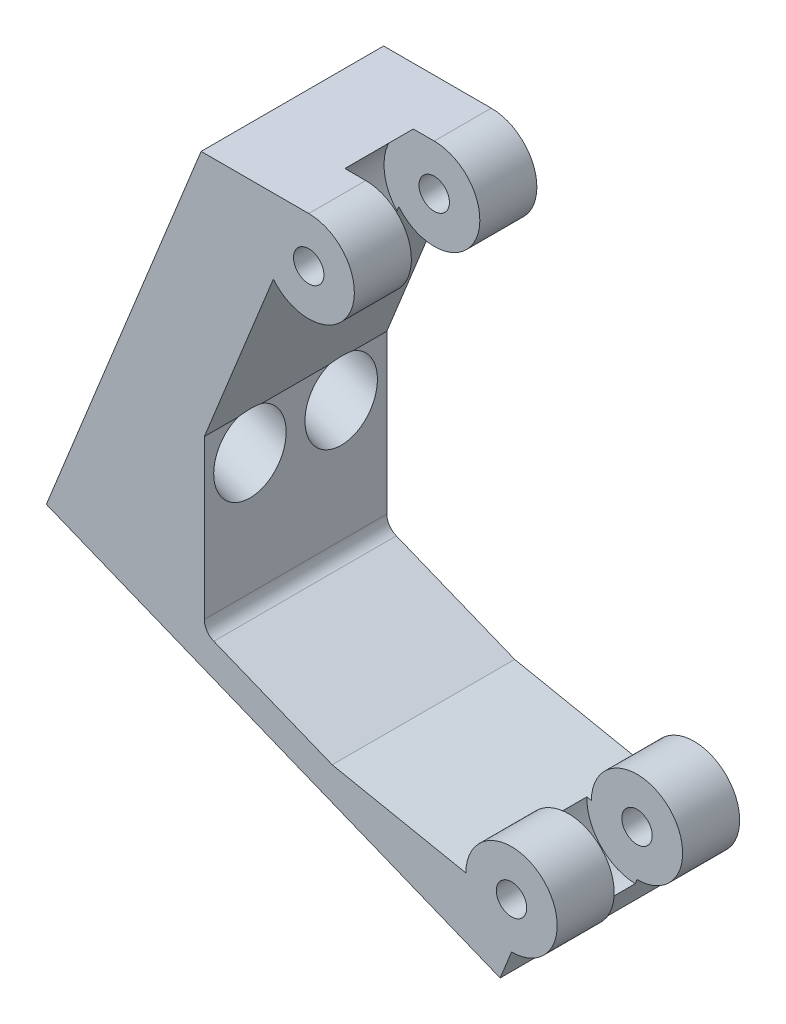
from build123d import *

# Parameters (mm, degrees)
SKETCH1_R                     = 1
BOSS_EXTRUDE1_DEPTH           = 12
SKETCH2_R                     = 3.3
CUT_EXTRUDE1_DEPTH            = 2.25
CUT_EXTRUDE1_DEPTH_BACK       = 2.25
FILLET3_R                     = 1
BOSS_EXTRUDE2_REACH           = 51.61
SKETCH4_W                     = 12
SKETCH4_H                     = 26.489515253
HOLE_SKETCH_R                 = 1.288405797
SCREW_SHAFT_HOLES_DEPTH       = 42.118659034
SCREW_SHAFT_HOLES_DEPTH_BACK  = 42.118659034
SKETCH5_R                     = 2.38125
SCREW_COUNTERBORES_DEPTH      = 5
SCREW_COUNTERBORES_DEPTH_BACK = 2.591836735
SKETCH6_W                     = 18.725223932
SKETCH6_H                     = 35.053619202
CUT_EXTRUDE2_DEPTH            = 1.66


with BuildPart() as part:
    # Sketch1 → Boss-Extrude1 (new body)
    with BuildSketch(Plane.XY):
        with BuildLine():
            Line((0, 6.640670196), (0, 35.210532713))
            Line((0, 35.210532713), (8.865440207, 35.210532713))
            ThreePointArc((8.865440207, 35.210532713), (11.575609349, 30.924071201), (6.541088012, 30.31385486))
            Line((6.541088012, 30.31385486), (2, 19.07426762))
            Line((2, 19.07426762), (2, 7.989687229))
            Line((2, 7.989687229), (10.406938735, 4.593063501))
            Line((10.406938735, 4.593063501), (19.199232805, 2.828667434))
            ThreePointArc((19.199232805, 2.828667434), (24.320553148, 4.949987778), (22.199232805, -0.171332566))
            Line((22.199232805, -0.171332566), (21.450019618, -2.025700275))
            Line((21.450019618, -2.025700275), (0, 6.640670196))
        make_face()
        with Locations((8.865440207, 32.210532713)):
            Circle(SKETCH1_R, mode=Mode.SUBTRACT)
        with Locations((22.199232805, 2.828667434)):
            Circle(SKETCH1_R, mode=Mode.SUBTRACT)
    extrude(amount=BOSS_EXTRUDE1_DEPTH)

    # Sketch2 → Cut-Extrude1 (cut, two sides)
    with BuildSketch(Plane.XY.offset(6)) as cut_extrude1_sk:
        with Locations((8.865440207, 32.210532713)):
            Circle(SKETCH2_R)
        with Locations((22.199232805, 2.828667434)):
            Circle(SKETCH2_R)
    extrude(amount=CUT_EXTRUDE1_DEPTH, mode=Mode.SUBTRACT)
    extrude(cut_extrude1_sk.sketch, amount=-CUT_EXTRUDE1_DEPTH_BACK, mode=Mode.SUBTRACT)

    # Fillet3
    fillet3_edges = [part.edges().sort_by_distance(p)[0] for p in [
        (2, 7.989687229, 6),
    ]]
    fillet(fillet3_edges, radius=FILLET3_R)

    # Boss-Extrude2: up to this face of the body (flat: up to its plane)
    boss_extrude2_end = Plane(part.part.faces().sort_by_distance((0, 20.925601454, 6))[0])
    # Sketch4 → Boss-Extrude2 (add, up to the picked face)
    with BuildSketch(Plane(origin=(-12.229645639, 4.941097571, 0), x_dir=(0, 0, -1), z_dir=(-0.9271838545667871, 0.37460659341591285, 0)), mode=Mode.PRIVATE) as boss_extrude2_sk1:
        with Locations((-6, -19.401879815)):
            Rectangle(SKETCH4_W, SKETCH4_H)
    boss_extrude2_tool1 = split(extrude(boss_extrude2_sk1.sketch, amount=-BOSS_EXTRUDE2_REACH, mode=Mode.PRIVATE), bisect_by=boss_extrude2_end, keep=Keep.BOTH, mode=Mode.PRIVATE)
    add(boss_extrude2_tool1.solids().sort_by(Axis((-4.961574, 22.930207, 6), (0.9271838545667871, -0.37460659341591285, 0)))[0])

    # Hole sketch → Screw shaft holes (cut, two sides)
    with BuildSketch(Plane(origin=(7.68361222, 33.141701506, 0), x_dir=(0, 0, -1), z_dir=(-0.927183854566786, 0.3746065934159158, 0))) as screw_shaft_holes_sk:
        with Locations(Location((-9, 17.420162392, 0), (0, 0, 270))):
            Circle(HOLE_SKETCH_R)
        with Locations(Location((-3, 17.420162392, 0), (0, 0, 270))):
            Circle(HOLE_SKETCH_R)
        with Locations(Location((-6, 6.887654186, 0), (0, 0, 90))):
            Circle(HOLE_SKETCH_R)
    extrude(amount=SCREW_SHAFT_HOLES_DEPTH, mode=Mode.SUBTRACT)
    extrude(screw_shaft_holes_sk.sketch, amount=-SCREW_SHAFT_HOLES_DEPTH_BACK, mode=Mode.SUBTRACT)

    # Sketch5 → Screw counterbores (cut, two sides)
    with BuildSketch(Plane(origin=(-4.905710031, 1.982035509, 0), x_dir=(0, 0, -1), z_dir=(0.927183854566786, -0.3746065934159158, 0))) as screw_counterbores_sk:
        with Locations(Location((-6, 26.719128162, 0), (0, 0, 270))):
            Circle(SKETCH5_R)
        with Locations(Location((-9, 16.186619957, 0), (0, 0, 109.262094827))):
            Circle(SKETCH5_R)
        with Locations(Location((-3, 16.186619957, 0), (0, 0, 109.262094827))):
            Circle(SKETCH5_R)
    extrude(amount=SCREW_COUNTERBORES_DEPTH, mode=Mode.SUBTRACT)
    extrude(screw_counterbores_sk.sketch, amount=-SCREW_COUNTERBORES_DEPTH_BACK, mode=Mode.SUBTRACT)

    # Sketch6 → Cut-Extrude2 (cut)
    with BuildSketch(Plane(origin=(-12.229645639, 4.941097571, 0), x_dir=(0, 0, 1), z_dir=(-0.9271838545667871, 0.37460659341591296, 0))):
        with Locations((5.962549552, 20.221942298)):
            Rectangle(SKETCH6_W, SKETCH6_H)
    extrude(amount=-CUT_EXTRUDE2_DEPTH, mode=Mode.SUBTRACT)


solid = part.part
